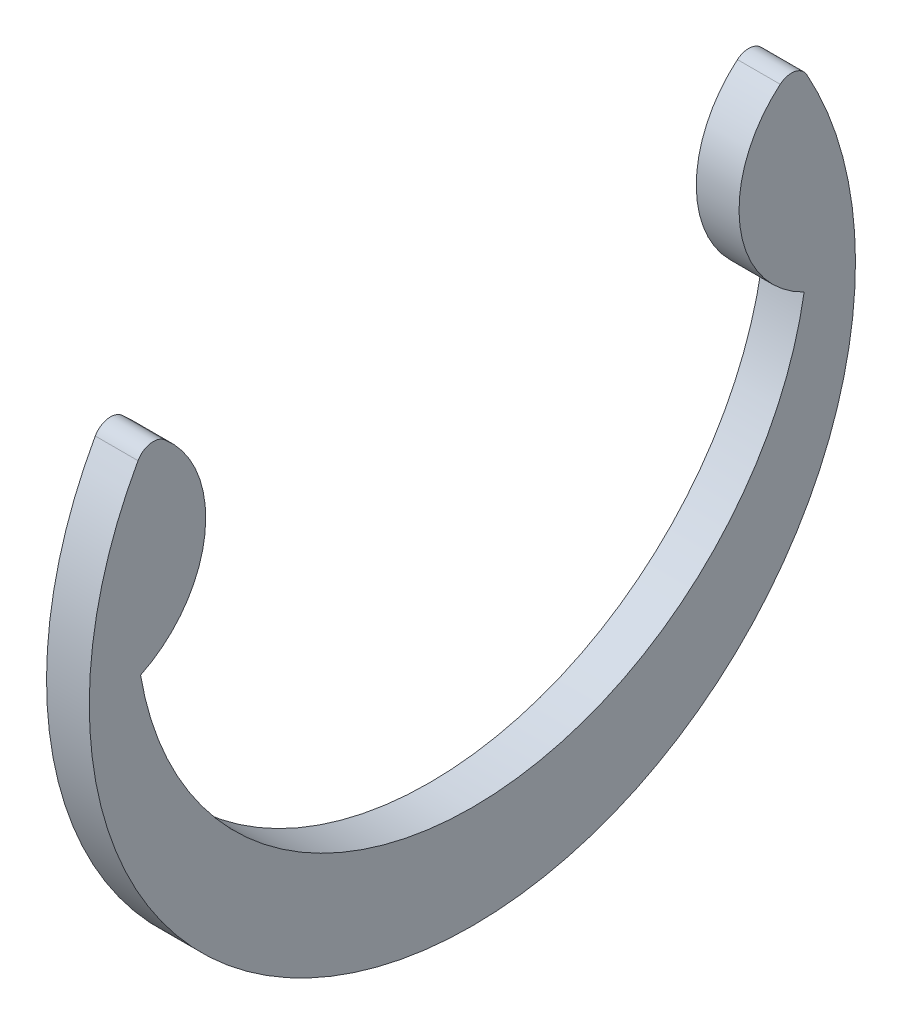
from build123d import *

# Parameters (mm, degrees)
EXTRUDE1_DEPTH = 0.3175


with BuildPart() as part:
    # Sketch1 → Extrude1 (new body, symmetric)
    with BuildSketch(Plane(origin=(0, 0, 0), x_dir=(0, 0, -1), z_dir=(1, 0, 0))):
        with BuildLine():
            ThreePointArc((-4.9276, 0), (0, -4.1656), (4.9276, 0))
            ThreePointArc((4.9276, 0), (3.973438211, 1.327826383), (4.571805292, 2.849504554))
            ThreePointArc((4.571805292, 2.849504554), (4.785847498, 2.905923889), (4.965828117, 2.777066667))
            ThreePointArc((4.965828117, 2.777066667), (0, -5.6896), (-4.965828117, 2.777066667))
            ThreePointArc((-4.965828117, 2.777066667), (-4.785847498, 2.905923889), (-4.571805292, 2.849504554))
            ThreePointArc((-4.571805292, 2.849504554), (-3.973438211, 1.327826383), (-4.9276, 0))
        make_face()
    extrude(amount=EXTRUDE1_DEPTH, both=True)


solid = part.part
